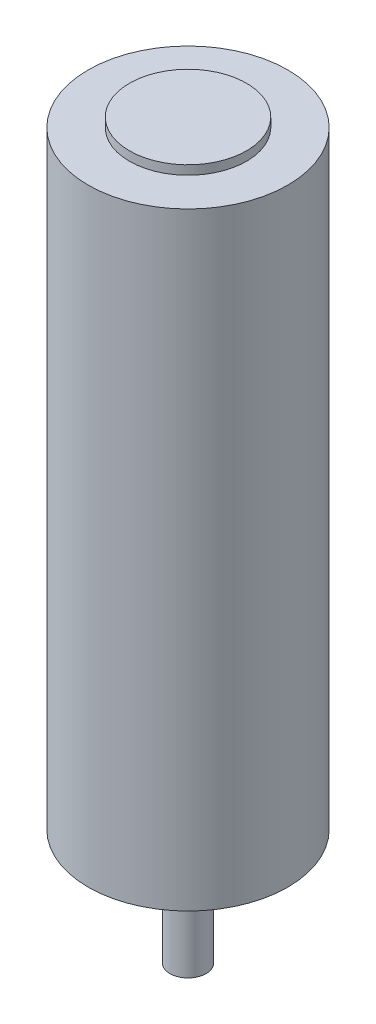
from build123d import *

# Parameters (mm, degrees)
SKETCH1_R                 = 11
BOSS_EXTRUDE1_DEPTH       = 33.5
SKETCH2_R                 = 6.45
BOSS_EXTRUDE2_DEPTH       = 1
SKETCH3_R                 = 6
BOSS_EXTRUDE3_DEPTH       = 1
SKETCH4_R                 = 3.25
BOSS_EXTRUDE4_DEPTH       = 1.5
SKETCH5_R                 = 2
BOSS_EXTRUDE5_DEPTH       = 10.25
M3X0_5_TAPPED_HOLE1_D     = 2.5
M3X0_5_TAPPED_HOLE1_DEPTH = 7
M3X0_5_TAPPED_HOLE1_TIP   = 0.751075774


with BuildPart() as part:
    # Sketch1 → Boss-Extrude1 (new body, symmetric)
    with BuildSketch(Plane(origin=(0, 0, 0), x_dir=(1, 0, 0), z_dir=(0, 1, 0))):
        Circle(SKETCH1_R)
    extrude(amount=BOSS_EXTRUDE1_DEPTH, both=True)

    # Sketch2 → Boss-Extrude2 (add)
    with BuildSketch(Plane(origin=(0, 33.5, 0), x_dir=(1, 0, 0), z_dir=(0, 1, 0))):
        Circle(SKETCH2_R)
    extrude(amount=BOSS_EXTRUDE2_DEPTH)

    # Sketch3 → Boss-Extrude3 (add)
    with BuildSketch(Plane.XZ.offset(33.5)):
        Circle(SKETCH3_R)
    extrude(amount=BOSS_EXTRUDE3_DEPTH)

    # Sketch4 → Boss-Extrude4 (add)
    with BuildSketch(Plane.XZ.offset(34.5)):
        Circle(SKETCH4_R)
    extrude(amount=BOSS_EXTRUDE4_DEPTH)

    # Sketch5 → Boss-Extrude5 (add)
    with BuildSketch(Plane(origin=(0, -36, 0), x_dir=(-1, 0, 0), z_dir=(0, -1, 0))):
        Circle(SKETCH5_R)
    extrude(amount=BOSS_EXTRUDE5_DEPTH)

    # M3x0.5 Tapped Hole1
    with Locations(Plane(origin=(0, -33.5, 0), x_dir=(-1, 0, 0), z_dir=(0, -1, 0))):
        with Locations((-7.25, 4.185631643), (7.25, 4.185631643), (0, -8.371736712)):
            Hole(M3X0_5_TAPPED_HOLE1_D / 2, depth=M3X0_5_TAPPED_HOLE1_DEPTH)
            with Locations((0, 0, -(M3X0_5_TAPPED_HOLE1_DEPTH + M3X0_5_TAPPED_HOLE1_TIP / 2))):  # 118° drill point
                Cone(0, M3X0_5_TAPPED_HOLE1_D / 2, M3X0_5_TAPPED_HOLE1_TIP, mode=Mode.SUBTRACT)


solid = part.part
